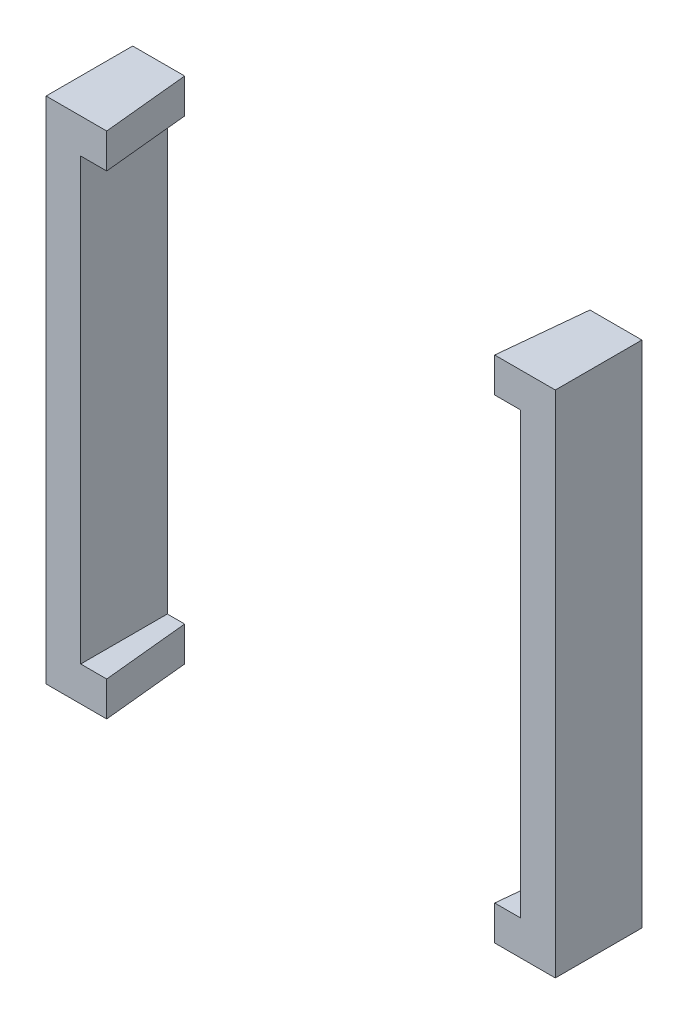
from build123d import *

# Parameters (mm, degrees)
SKETCH_4_W               = 29.4
SKETCH_4_H               = 29.4
SKETCH_4_W_2             = 25.4
SKETCH_4_H_2             = 25.4
EXTRUDE_1_DEPTH          = 5
CUT_EXTRUDE_1_DEPTH      = 28.4
CUT_EXTRUDE_1_DEPTH_BACK = 3


with BuildPart() as part:
    # 草图4 → 拉伸-薄壁1 (new body)
    with BuildSketch(Plane.XY):
        with Locations((12.7, 12.7)):
            Rectangle(SKETCH_4_W, SKETCH_4_H)
        with Locations((12.7, 12.7)):
            Rectangle(SKETCH_4_W_2, SKETCH_4_H_2, mode=Mode.SUBTRACT)
    extrude(amount=EXTRUDE_1_DEPTH)

    # 草图5 → 切除-拉伸1 (cut, two sides)
    with BuildSketch(Plane(origin=(0, 0, 0), x_dir=(1, 0, 0), z_dir=(0, 1, 0))) as cut_extrude_1_sk:
        Polygon((1, 0), (1.5, -5), (23.9, -5), (24.4, 0), align=None)
    extrude(amount=CUT_EXTRUDE_1_DEPTH, mode=Mode.SUBTRACT)
    extrude(cut_extrude_1_sk.sketch, amount=-CUT_EXTRUDE_1_DEPTH_BACK, mode=Mode.SUBTRACT)


solid = part.part
